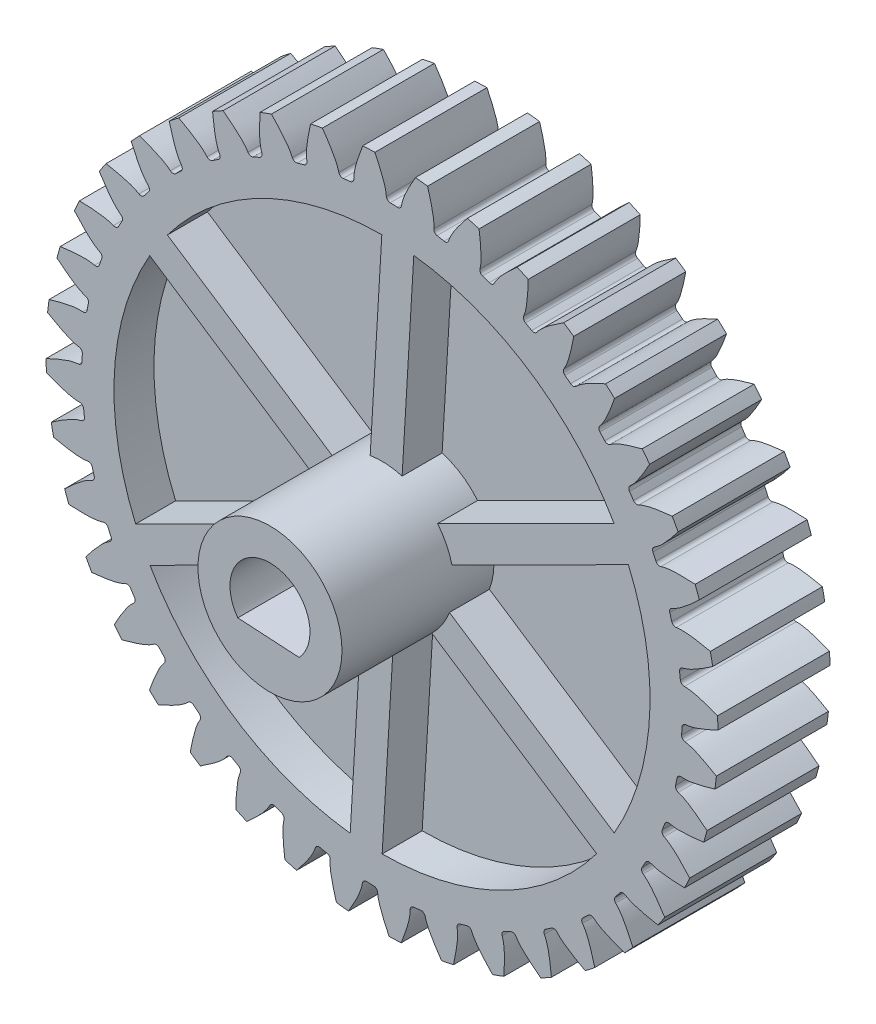
from build123d import *

# Parameters (mm, degrees)
ESQUISSE1_R                        = 18.75
BASE_EXTRUSION_DEPTH               = 3.5
ESQUISSE8_R                        = 16.75
ENL_V_MAT_EXTRU_4_DEPTH            = 2.5
BOSS_EXTRU_1_DEPTH                 = 3.5
CONG_1_R                           = 0.25
R_P_TITION_CIRCULAIRE1_COUNT       = 40
CONG_1_OF_R_P_TITION_CIRCULAIRE1_R = 0.25
ENL_V_MAT_EXTRU_2_DEPTH            = 30.89744792
ENL_V_MAT_EXTRU_2_DEPTH_BACK       = 30.89744792
BOSS_EXTRU_2_START                 = -7
ESQUISSE5_R                        = 4.5
BOSS_EXTRU_2_DEPTH                 = 14
NERVURE1_REACH                     = 34.827


with BuildPart() as part:
    # Esquisse1 → Base-Extrusion (new, symmetric)
    with BuildSketch(Plane.XY):
        Circle(ESQUISSE1_R)
    extrude(amount=BASE_EXTRUSION_DEPTH, both=True)

    # Esquisse8 → Enlèv. mat.-Extru.4 (cut)
    with BuildSketch(Plane(origin=(0, 0, -3.5), x_dir=(-1, 0, 0), z_dir=(0, 0, -1))):
        Circle(ESQUISSE8_R)
    enl_v_mat_extru_4 = extrude(amount=-ENL_V_MAT_EXTRU_4_DEPTH, mode=Mode.SUBTRACT)

    # Symétrie1: Enlèv. mat.-Extru.4 across plane
    add(enl_v_mat_extru_4.mirror(Plane.XY), mode=Mode.SUBTRACT)

    # Esquisse2 → Boss.-Extru.1 (add, symmetric)
    with BuildSketch(Plane.XY):
        with BuildLine():
            Line((17.070349214, 1.068086499), (17.101566342, 0.272139142))
            add(Edge.make_bspline(
                [(17.101566342, 0.272139142), (17.26335523, 0.191453025), (17.793501578, -0.072937511), (18.791627166, -0.415576439), (19.970266757, -0.039520507), (20.668706101, 0.289297914), (20.995325468, 0.443067122)],
                knots=[0, 0, 0, 0, 0.13238796, 0.43380602, 0.735224081, 1, 1, 1, 1], degree=3))
            ThreePointArc((20.995325468, 0.443067122), (20.983867346, 0.822989189), (20.965534886, 1.202641644))
            add(Edge.make_bspline(
                [(17.070349214, 1.068086499), (17.22532182, 1.161196032), (17.733132725, 1.466295345), (18.701356983, 1.886054694), (19.905828731, 1.603464605), (20.627875638, 1.330357784), (20.965534886, 1.202641644)],
                knots=[0, 0, 0, 0, 0.13238796, 0.43380602, 0.735224081, 1, 1, 1, 1], degree=3))
        make_face()
    boss_extru_1 = extrude(amount=BOSS_EXTRU_1_DEPTH, both=True)

    # Congé1
    cong_1_edges = [part.edges().sort_by_distance(p)[0] for p in [
        (18.747924448, -0.278978333, 1.7499997),
        (18.668486831, 1.746453393, 1.7499997),
    ]]
    fillet(cong_1_edges, radius=CONG_1_R)

    # Répétition circulaire1: Boss.-Extru.1 ×40 about axis
    r_p_tition_circulaire1_axis = Axis((0, 0, -50), (0, 0, 1))
    for i in range(1, R_P_TITION_CIRCULAIRE1_COUNT):
        add(boss_extru_1.rotate(r_p_tition_circulaire1_axis, i * 360 / R_P_TITION_CIRCULAIRE1_COUNT))

    # Congé1 of Répétition circulaire1
    cong_1_of_r_p_tition_circulaire1_edges = [part.edges().sort_by_distance(p)[0] for p in [
        (18.560748214, 2.657277884, 1.7499997),
        (18.165441277, 4.645346404, 1.7499997),
        (17.916544759, 5.528103102, 1.7499997),
        (17.215102271, 7.42985557, 1.7499997),
        (16.831176511, 8.262808074, 1.7499997),
        (15.840870314, 10.031417033, 1.7499997),
        (15.331368837, 10.794055289, 1.7499997),
        (14.076583557, 12.385971716, 1.7499997),
        (13.454051981, 13.059517039, 1.7499997),
        (11.965684595, 14.43554267, 1.7499997),
        (11.245451714, 15.003410137, 1.7499997),
        (9.560150767, 16.129662653, 1.7499997),
        (8.759951104, 16.577869485, 1.7499997),
        (6.919214298, 17.426616811, 1.7499997),
        (6.058751425, 17.744126667, 1.7499997),
        (4.10790381, 18.294469828, 1.7499997),
        (3.208365179, 18.473464561, 1.7499997),
        (1.195443097, 18.711852281, 1.7499997),
        (0.278978333, 18.747924448, 1.7499997),
        (-1.746453393, 18.668486831, 1.7499997),
        (-2.657277884, 18.560748214, 1.7499997),
        (-4.645346404, 18.165441277, 1.7499997),
        (-5.528103102, 17.916544759, 1.7499997),
        (-7.42985557, 17.215102271, 1.7499997),
        (-8.262808074, 16.831176511, 1.7499997),
        (-10.031417033, 15.840870314, 1.7499997),
        (-10.794055289, 15.331368837, 1.7499997),
        (-12.385971716, 14.076583557, 1.7499997),
        (-13.059517039, 13.454051981, 1.7499997),
        (-14.43554267, 11.965684595, 1.7499997),
        (-15.003410137, 11.245451714, 1.7499997),
        (-16.129662653, 9.560150767, 1.7499997),
        (-16.577869485, 8.759951104, 1.7499997),
        (-17.426616811, 6.919214298, 1.7499997),
        (-17.744126667, 6.058751425, 1.7499997),
        (-18.294469828, 4.10790381, 1.7499997),
        (-18.473464561, 3.208365179, 1.7499997),
        (-18.711852281, 1.195443097, 1.7499997),
        (-18.747924448, 0.278978333, 1.7499997),
        (-18.668486831, -1.746453393, 1.7499997),
        (-18.560748214, -2.657277884, 1.7499997),
        (-18.165441277, -4.645346404, 1.7499997),
        (-17.916544759, -5.528103102, 1.7499997),
        (-17.215102271, -7.42985557, 1.7499997),
        (-16.831176511, -8.262808074, 1.7499997),
        (-15.840870314, -10.031417033, 1.7499997),
        (-15.331368837, -10.794055289, 1.7499997),
        (-14.076583557, -12.385971716, 1.7499997),
        (-13.454051981, -13.059517039, 1.7499997),
        (-11.965684595, -14.43554267, 1.7499997),
        (-11.245451714, -15.003410137, 1.7499997),
        (-9.560150767, -16.129662653, 1.7499997),
        (-8.759951104, -16.577869485, 1.7499997),
        (-6.919214298, -17.426616811, 1.7499997),
        (-6.058751425, -17.744126667, 1.7499997),
        (-4.10790381, -18.294469828, 1.7499997),
        (-3.208365179, -18.473464561, 1.7499997),
        (-1.195443097, -18.711852281, 1.7499997),
        (-0.278978333, -18.747924448, 1.7499997),
        (1.746453393, -18.668486831, 1.7499997),
        (2.657277884, -18.560748214, 1.7499997),
        (4.645346404, -18.165441277, 1.7499997),
        (5.528103102, -17.916544759, 1.7499997),
        (7.42985557, -17.215102271, 1.7499997),
        (8.262808074, -16.831176511, 1.7499997),
        (10.031417033, -15.840870314, 1.7499997),
        (10.794055289, -15.331368837, 1.7499997),
        (12.385971716, -14.076583557, 1.7499997),
        (13.059517039, -13.454051981, 1.7499997),
        (14.43554267, -11.965684595, 1.7499997),
        (15.003410137, -11.245451714, 1.7499997),
        (16.129662653, -9.560150767, 1.7499997),
        (16.577869485, -8.759951104, 1.7499997),
        (17.426616811, -6.919214298, 1.7499997),
        (17.744126667, -6.058751425, 1.7499997),
        (18.294469828, -4.10790381, 1.7499997),
        (18.473464561, -3.208365179, 1.7499997),
        (18.711852281, -1.195443097, 1.7499997),
    ]]
    fillet(cong_1_of_r_p_tition_circulaire1_edges, radius=CONG_1_OF_R_P_TITION_CIRCULAIRE1_R)

    # Esquisse3 → Enlèv. mat.-Extru.2 (cut, two sides)
    with BuildSketch(Plane.XY) as enl_v_mat_extru_2_sk:
        with BuildLine():
            Line((-2.012131231, -1.483687268), (1.823029255, -1.710720415))
            ThreePointArc((1.823029255, -1.710720415), (0.147735919, 2.495631002), (-2.012131231, -1.483687268))
        make_face()
    extrude(amount=ENL_V_MAT_EXTRU_2_DEPTH, mode=Mode.SUBTRACT)
    extrude(enl_v_mat_extru_2_sk.sketch, amount=-ENL_V_MAT_EXTRU_2_DEPTH_BACK, mode=Mode.SUBTRACT)

    # Esquisse5 → Boss.-Extru.2 (add)
    with BuildSketch(Plane.XY.offset(3.5).offset(BOSS_EXTRU_2_START)):
        Circle(ESQUISSE5_R)
        with BuildLine():
            Line((-2.012131231, -1.483687268), (1.823029255, -1.710720415))
            ThreePointArc((1.823029255, -1.710720415), (0.147735919, 2.495631002), (-2.012131231, -1.483687268))
        make_face(mode=Mode.SUBTRACT)
    extrude(amount=BOSS_EXTRU_2_DEPTH)

    # Esquisse7 walls → Nervure1 (add, up to next)
    with BuildSketch(Plane(origin=(0, 0, -3.5), x_dir=(-1, 0, 0), z_dir=(0, 0, -1)), mode=Mode.PRIVATE) as nervure1_sk1:
        Polygon((-2.731308835, 29.216584798), (1.990559345, -50.547637051), (3.987064147, -50.429448316), (-0.734804034, 29.334773534), align=None)
    nervure1_tool1 = extrude(nervure1_sk1.sketch, amount=-NERVURE1_REACH, mode=Mode.PRIVATE) - part.part
    # Esquisse7 walls → Nervure1 (add, up to next)
    with BuildSketch(Plane(origin=(0, 0, -3.5), x_dir=(-1, 0, 0), z_dir=(0, 0, -1)), mode=Mode.PRIVATE) as nervure1_sk2:
        Polygon((23.93665023, 16.973675236), (-42.780258115, -26.997693486), (-41.679651267, -28.667622996), (25.037257078, 15.303745727), align=None)
    nervure1_tool2 = extrude(nervure1_sk2.sketch, amount=-NERVURE1_REACH, mode=Mode.PRIVATE) - part.part
    # Esquisse7 walls → Nervure1 (add, up to next)
    with BuildSketch(Plane(origin=(0, 0, -3.5), x_dir=(-1, 0, 0), z_dir=(0, 0, -1)), mode=Mode.PRIVATE) as nervure1_sk3:
        Polygon((26.667959065, -12.242909562), (-44.77081746, 23.549943565), (-45.666715414, 21.76182532), (25.772061111, -14.031027807), align=None)
    nervure1_tool3 = extrude(nervure1_sk3.sketch, amount=-NERVURE1_REACH, mode=Mode.PRIVATE) - part.part
    # Esquisse7 walls → Nervure1 (add, up to next)
    with BuildSketch(Plane(origin=(0, 0, -3.5), x_dir=(-1, 0, 0), z_dir=(0, 0, -1)), mode=Mode.PRIVATE) as nervure1_sk4:
        Polygon((2.731308835, -29.216584798), (-1.990559345, 50.547637051), (-3.987064147, 50.429448316), (0.734804034, -29.334773534), align=None)
    nervure1_tool4 = extrude(nervure1_sk4.sketch, amount=-NERVURE1_REACH, mode=Mode.PRIVATE) - part.part
    # Esquisse7 walls → Nervure1 (add, up to next)
    with BuildSketch(Plane(origin=(0, 0, -3.5), x_dir=(-1, 0, 0), z_dir=(0, 0, -1)), mode=Mode.PRIVATE) as nervure1_sk5:
        Polygon((-23.93665023, -16.973675236), (42.780258115, 26.997693486), (41.679651267, 28.667622996), (-25.037257078, -15.303745727), align=None)
    nervure1_tool5 = extrude(nervure1_sk5.sketch, amount=-NERVURE1_REACH, mode=Mode.PRIVATE) - part.part
    # Esquisse7 walls → Nervure1 (add, up to next)
    with BuildSketch(Plane(origin=(0, 0, -3.5), x_dir=(-1, 0, 0), z_dir=(0, 0, -1)), mode=Mode.PRIVATE) as nervure1_sk6:
        Polygon((-26.667959065, 12.242909562), (44.77081746, -23.549943565), (45.666715414, -21.76182532), (-25.772061111, 14.031027807), align=None)
    nervure1_tool6 = extrude(nervure1_sk6.sketch, amount=-NERVURE1_REACH, mode=Mode.PRIVATE) - part.part
    nervure1_1 = nervure1_tool1.solids().sort_by_distance((-0.627877656, -10.606431759, -3.5))[0]
    add(nervure1_1)
    nervure1_2 = nervure1_tool2.solids().sort_by_distance((8.871500519, -5.84697388, -3.5))[0]
    add(nervure1_2)
    nervure1_3 = nervure1_tool3.solids().sort_by_distance((9.499378174, 4.759457879, -3.5))[0]
    add(nervure1_3)
    nervure1_4 = nervure1_tool4.solids().sort_by_distance((0.627877656, 10.606431759, -3.5))[0]
    add(nervure1_4)
    nervure1_5 = nervure1_tool5.solids().sort_by_distance((-8.871500519, 5.84697388, -3.5))[0]
    add(nervure1_5)
    nervure1_6 = nervure1_tool6.solids().sort_by_distance((-9.499378174, -4.759457879, -3.5))[0]
    add(nervure1_6)
    nervure1 = nervure1_1 + nervure1_2 + nervure1_3 + nervure1_4 + nervure1_5 + nervure1_6  # Nervure1 as one shape, for the pattern or mirror that repeats it

    # Symétrie2: Nervure1 across plane
    add(nervure1.mirror(Plane.XY))


solid = part.part
